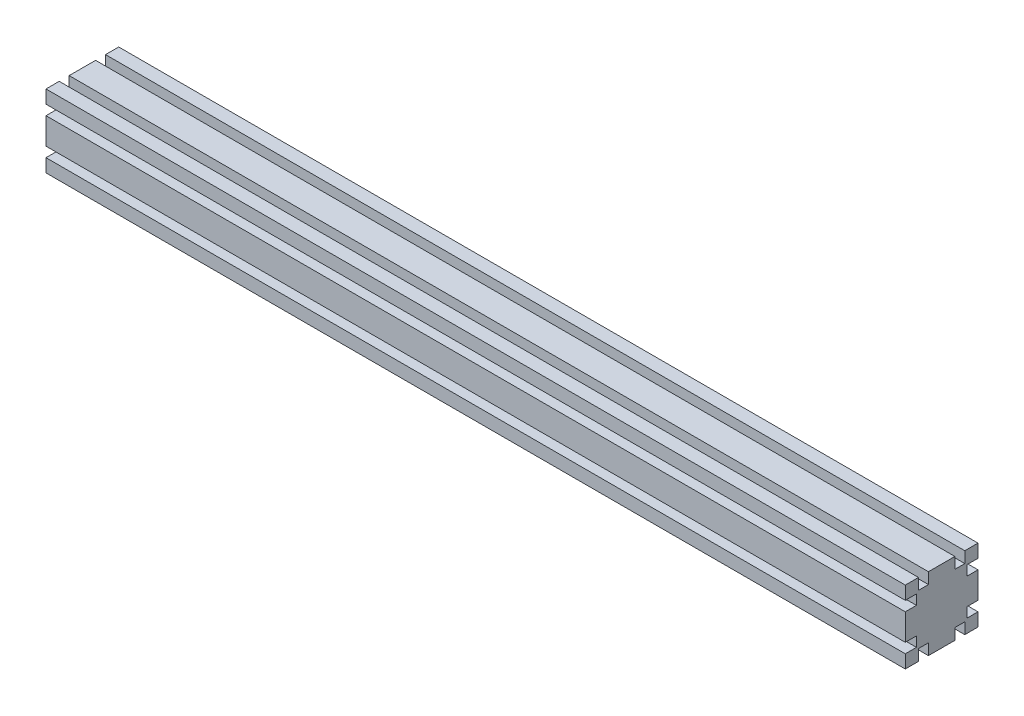
from build123d import *

# Parameters (mm, degrees)
SKETCH_1_W          = 60
SKETCH_1_H          = 60
EXTRUDE_1_DEPTH     = 709
SKETCH_2_W          = 8.2
SKETCH_2_H          = 9.2
SKETCH_2_W_2        = 9.2
SKETCH_2_H_2        = 8.2
CUT_EXTRUDE_1_DEPTH = 710


with BuildPart() as part:
    # 草图1 → 凸台-拉伸1 (new body)
    with BuildSketch(Plane(origin=(0, 0, 0), x_dir=(0, 0, -1), z_dir=(1, 0, 0))):
        Rectangle(SKETCH_1_W, SKETCH_1_H)
    extrude(amount=EXTRUDE_1_DEPTH)

    # 草图2 → 切除-拉伸1 (cut, through all)
    with BuildSketch(Plane.ZY):
        with Locations((-15, 25.4)):
            Rectangle(SKETCH_2_W, SKETCH_2_H)
        with Locations((-15, -25.4)):
            Rectangle(SKETCH_2_W, SKETCH_2_H)
        with Locations((15, -25.4)):
            Rectangle(SKETCH_2_W, SKETCH_2_H)
        with Locations((15, 25.4)):
            Rectangle(SKETCH_2_W, SKETCH_2_H)
        with Locations((-25.4, 15)):
            Rectangle(SKETCH_2_W_2, SKETCH_2_H_2)
        with Locations((-25.4, -15)):
            Rectangle(SKETCH_2_W_2, SKETCH_2_H_2)
        with Locations((25.4, -15)):
            Rectangle(SKETCH_2_W_2, SKETCH_2_H_2)
        with Locations((25.4, 15)):
            Rectangle(SKETCH_2_W_2, SKETCH_2_H_2)
    extrude(amount=-CUT_EXTRUDE_1_DEPTH, mode=Mode.SUBTRACT)


solid = part.part
